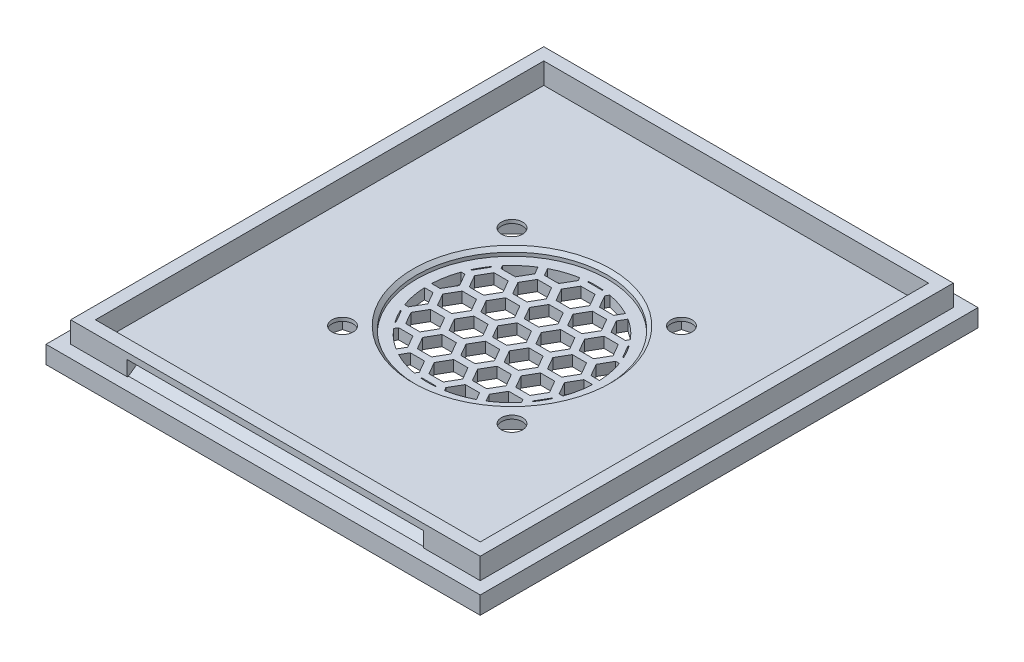
from build123d import *

# Parameters (mm, degrees)
SKETCH1_W           = 61.5
SKETCH1_H           = 70.5
SKETCH1_R           = 1.5
BOSS_EXTRUDE1_DEPTH = 2.5
SKETCH2_W           = 58
SKETCH2_H           = 67
SKETCH2_W_2         = 54.5
SKETCH2_H_2         = 63.5
BOSS_EXTRUDE2_DEPTH = 3
CUT_EXTRUDE1_DEPTH  = 2
SKETCH6_R           = 13.5
CUT_EXTRUDE7_DEPTH  = 1
CHAMFER1_SIZE       = 0.5
CUT_EXTRUDE8_DEPTH  = 1.5
CUT_EXTRUDE9_DEPTH  = 21


with BuildPart() as part:
    # Sketch1 → Boss-Extrude1 (new body)
    with BuildSketch(Plane(origin=(0, 0, 0), x_dir=(1, 0, 0), z_dir=(0, 1, 0))):
        Rectangle(SKETCH1_W, SKETCH1_H)
        with Locations((-12, 12)):
            Circle(SKETCH1_R, mode=Mode.SUBTRACT)
        with Locations((-12, -12)):
            Circle(SKETCH1_R, mode=Mode.SUBTRACT)
        with Locations((12, -12)):
            Circle(SKETCH1_R, mode=Mode.SUBTRACT)
        with Locations((12, 12)):
            Circle(SKETCH1_R, mode=Mode.SUBTRACT)
    extrude(amount=BOSS_EXTRUDE1_DEPTH)

    # Sketch2 → Boss-Extrude2 (add)
    with BuildSketch(Plane(origin=(0, 2.5, 0), x_dir=(1, 0, 0), z_dir=(0, 1, 0))):
        Rectangle(SKETCH2_W, SKETCH2_H)
        Rectangle(SKETCH2_W_2, SKETCH2_H_2, mode=Mode.SUBTRACT)
    extrude(amount=BOSS_EXTRUDE2_DEPTH)

    # Sketch3 → Cut-Extrude1 (cut)
    with BuildSketch(Plane.XZ):
        Polygon((-11.252853773, 9.211612321), (-9.211612321, 11.252853773), (-9.958758548, 14.041241452), (-12.747146227, 14.788387679), (-14.788387679, 12.747146227), (-14.041241452, 9.958758548), align=None)
        Polygon((9.211612321, 11.252853773), (11.252853773, 9.211612321), (14.041241452, 9.958758548), (14.788387679, 12.747146227), (12.747146227, 14.788387679), (9.958758548, 14.041241452), align=None)
        Polygon((11.252853773, -9.211612321), (9.211612321, -11.252853773), (9.958758548, -14.041241452), (12.747146227, -14.788387679), (14.788387679, -12.747146227), (14.041241452, -9.958758548), align=None)
        Polygon((-9.211612321, -11.252853773), (-11.252853773, -9.211612321), (-14.041241452, -9.958758548), (-14.788387679, -12.747146227), (-12.747146227, -14.788387679), (-9.958758548, -14.041241452), align=None)
    extrude(amount=-CUT_EXTRUDE1_DEPTH, mode=Mode.SUBTRACT)

    # Sketch6 → Cut-Extrude7 (cut)
    with BuildSketch(Plane(origin=(0, 2.5, 0), x_dir=(1, 0, 0), z_dir=(0, 1, 0))):
        Circle(SKETCH6_R)
    extrude(amount=-CUT_EXTRUDE7_DEPTH, mode=Mode.SUBTRACT)

    # Chamfer1
    chamfer1_edges = [part.edges().sort_by_distance(p)[0] for p in [
        (-13.5, 2.5, 0),
    ]]
    chamfer(chamfer1_edges, length=CHAMFER1_SIZE)

    # Sketch4 → Cut-Extrude8 (cut)
    with BuildSketch(Plane.XZ):
        with BuildLine():
            Line((10.680637029, 5), (10.804720311, 5))
            ThreePointArc((10.804720311, 5), (10.310421845, 5.952913772), (9.73229868, 6.857429796))
            Line((9.73229868, 6.857429796), (9.670274058, 6.75))
            Line((9.670274058, 6.75), (10.680637029, 5))
        make_face()
        with BuildLine():
            Line((10.680637029, 0.5), (11.895040185, 0.5))
            ThreePointArc((11.895040185, 0.5), (11.686032158, 2.275661089), (11.213473191, 4))
            Line((11.213473191, 4), (10.680637029, 4))
            Line((10.680637029, 4), (9.670274058, 2.25))
            Line((9.670274058, 2.25), (10.680637029, 0.5))
        make_face()
        Polygon((6.783637029, 2.75), (8.804362971, 2.75), (9.814725942, 4.5), (8.804362971, 6.25), (6.783637029, 6.25), (5.773274058, 4.5), align=None)
        with BuildLine():
            Line((8.804362971, 7.25), (9.070702049, 7.711312815))
            ThreePointArc((9.070702049, 7.711312815), (7.813642325, 8.982704193), (6.380365479, 10.051513187))
            Line((6.380365479, 10.051513187), (5.773274058, 9))
            Line((5.773274058, 9), (6.783637029, 7.25))
            Line((6.783637029, 7.25), (8.804362971, 7.25))
        make_face()
        Polygon((6.783637029, -1.75), (8.804362971, -1.75), (9.814725942, 0), (8.804362971, 1.75), (6.783637029, 1.75), (5.773274058, 0), align=None)
        with BuildLine():
            Line((10.680637029, -4), (11.213473191, -4))
            ThreePointArc((11.213473191, -4), (11.686032158, -2.275661089), (11.895040185, -0.5))
            Line((11.895040185, -0.5), (10.680637029, -0.5))
            Line((10.680637029, -0.5), (9.670274058, -2.25))
            Line((9.670274058, -2.25), (10.680637029, -4))
        make_face()
        Polygon((6.783637029, -6.25), (8.804362971, -6.25), (9.814725942, -4.5), (8.804362971, -2.75), (6.783637029, -2.75), (5.773274058, -4.5), align=None)
        with BuildLine():
            Line((5.773274058, -9), (6.380365479, -10.051513187))
            ThreePointArc((6.380365479, -10.051513187), (7.813642325, -8.982704193), (9.070702049, -7.711312815))
            Line((9.070702049, -7.711312815), (8.804362971, -7.25))
            Line((8.804362971, -7.25), (6.783637029, -7.25))
            Line((6.783637029, -7.25), (5.773274058, -9))
        make_face()
        with BuildLine():
            Line((1.876274058, -11.25), (2.142531585, -11.711171564))
            ThreePointArc((2.142531585, -11.711171564), (3.872139217, -11.25826447), (5.514419572, -10.551452876))
            Line((5.514419572, -10.551452876), (4.907362971, -9.5))
            Line((4.907362971, -9.5), (2.886637029, -9.5))
            Line((2.886637029, -9.5), (1.876274058, -11.25))
        make_face()
        Polygon((2.886637029, -5), (1.876274058, -6.75), (2.886637029, -8.5), (4.907362971, -8.5), (5.917725942, -6.75), (4.907362971, -5), align=None)
        Polygon((4.907362971, -0.5), (2.886637029, -0.5), (1.876274058, -2.25), (2.886637029, -4), (4.907362971, -4), (5.917725942, -2.25), align=None)
        Polygon((2.886637029, 4), (1.876274058, 2.25), (2.886637029, 0.5), (4.907362971, 0.5), (5.917725942, 2.25), (4.907362971, 4), align=None)
        Polygon((2.886637029, 8.5), (1.876274058, 6.75), (2.886637029, 5), (4.907362971, 5), (5.917725942, 6.75), (4.907362971, 8.5), align=None)
        with BuildLine():
            Line((4.907362971, 9.5), (5.514419572, 10.551452876))
            ThreePointArc((5.514419572, 10.551452876), (3.872139217, 11.25826447), (2.142531585, 11.711171564))
            Line((2.142531585, 11.711171564), (1.876274058, 11.25))
            Line((1.876274058, 11.25), (2.886637029, 9.5))
            Line((2.886637029, 9.5), (4.907362971, 9.5))
        make_face()
        Polygon((-1.010362971, 7.25), (1.010362971, 7.25), (2.020725942, 9), (1.010362971, 10.75), (-1.010362971, 10.75), (-2.020725942, 9), align=None)
        Polygon((-1.010362971, 2.75), (1.010362971, 2.75), (2.020725942, 4.5), (1.010362971, 6.25), (-1.010362971, 6.25), (-2.020725942, 4.5), align=None)
        Polygon((-1.010362971, 1.75), (-2.020725942, 0), (2.020725942, 0), (1.010362971, 1.75), align=None)
        Polygon((-2.020725942, 0), (2.020725942, 0), (1.010362971, -1.75), (-1.010362971, -1.75), align=None)
        Polygon((-1.010362971, -6.25), (1.010362971, -6.25), (2.020725942, -4.5), (1.010362971, -2.75), (-1.010362971, -2.75), (-2.020725942, -4.5), align=None)
        Polygon((-1.010362971, -10.75), (1.010362971, -10.75), (2.020725942, -9), (1.010362971, -7.25), (-1.010362971, -7.25), (-2.020725942, -9), align=None)
        with BuildLine():
            Line((-5.514419572, -10.551452876), (-4.907362971, -9.5))
            Line((-4.907362971, -9.5), (-2.886637029, -9.5))
            Line((-2.886637029, -9.5), (-1.876274058, -11.25))
            Line((-1.876274058, -11.25), (-2.142531585, -11.711171564))
            ThreePointArc((-2.142531585, -11.711171564), (-3.872139217, -11.25826447), (-5.514419572, -10.551452876))
        make_face()
        Polygon((-2.886637029, -8.5), (-4.907362971, -8.5), (-5.917725942, -6.75), (-4.907362971, -5), (-2.886637029, -5), (-1.876274058, -6.75), align=None)
        Polygon((-1.876274058, -2.25), (-2.886637029, -4), (-4.907362971, -4), (-5.917725942, -2.25), (-4.907362971, -0.5), (-2.886637029, -0.5), align=None)
        Polygon((-2.886637029, 0.5), (-4.907362971, 0.5), (-5.917725942, 2.25), (-4.907362971, 4), (-2.886637029, 4), (-1.876274058, 2.25), align=None)
        Polygon((-2.886637029, 5), (-4.907362971, 5), (-5.917725942, 6.75), (-4.907362971, 8.5), (-2.886637029, 8.5), (-1.876274058, 6.75), align=None)
        with BuildLine():
            Line((-2.142531585, 11.711171564), (-1.876274058, 11.25))
            Line((-1.876274058, 11.25), (-2.886637029, 9.5))
            Line((-2.886637029, 9.5), (-4.907362971, 9.5))
            Line((-4.907362971, 9.5), (-5.514419572, 10.551452876))
            ThreePointArc((-5.514419572, 10.551452876), (-3.872139217, 11.25826447), (-2.142531585, 11.711171564))
        make_face()
        with BuildLine():
            Line((-6.380365479, 10.051513187), (-5.773274058, 9))
            Line((-5.773274058, 9), (-6.783637029, 7.25))
            Line((-6.783637029, 7.25), (-8.804362971, 7.25))
            Line((-8.804362971, 7.25), (-9.070702049, 7.711312815))
            ThreePointArc((-9.070702049, 7.711312815), (-7.813642325, 8.982704193), (-6.380365479, 10.051513187))
        make_face()
        Polygon((-9.814725942, 4.5), (-8.804362971, 6.25), (-6.783637029, 6.25), (-5.773274058, 4.5), (-6.783637029, 2.75), (-8.804362971, 2.75), align=None)
        Polygon((-9.814725942, 0), (-8.804362971, 1.75), (-6.783637029, 1.75), (-5.773274058, 0), (-6.783637029, -1.75), (-8.804362971, -1.75), align=None)
        Polygon((-9.814725942, -4.5), (-8.804362971, -2.75), (-6.783637029, -2.75), (-5.773274058, -4.5), (-6.783637029, -6.25), (-8.804362971, -6.25), align=None)
        with BuildLine():
            Line((-9.070702049, -7.711312815), (-8.804362971, -7.25))
            Line((-8.804362971, -7.25), (-6.783637029, -7.25))
            Line((-6.783637029, -7.25), (-5.773274058, -9))
            Line((-5.773274058, -9), (-6.380365479, -10.051513187))
            ThreePointArc((-6.380365479, -10.051513187), (-7.813642325, -8.982704193), (-9.070702049, -7.711312815))
        make_face()
        with BuildLine():
            Line((-11.895040185, -0.5), (-10.680637029, -0.5))
            Line((-10.680637029, -0.5), (-9.670274058, -2.25))
            Line((-9.670274058, -2.25), (-10.680637029, -4))
            Line((-10.680637029, -4), (-11.213473191, -4))
            ThreePointArc((-11.213473191, -4), (-11.686032158, -2.275661089), (-11.895040185, -0.5))
        make_face()
        with BuildLine():
            Line((-11.213473191, 4), (-10.680637029, 4))
            Line((-10.680637029, 4), (-9.670274058, 2.25))
            Line((-9.670274058, 2.25), (-10.680637029, 0.5))
            Line((-10.680637029, 0.5), (-11.895040185, 0.5))
            ThreePointArc((-11.895040185, 0.5), (-11.686032158, 2.275661089), (-11.213473191, 4))
        make_face()
        with BuildLine():
            Line((10.680637029, -5), (9.670274058, -6.75))
            Line((9.670274058, -6.75), (9.73229868, -6.857429796))
            ThreePointArc((9.73229868, -6.857429796), (10.310421845, -5.952913772), (10.804720311, -5))
            Line((10.804720311, -5), (10.680637029, -5))
        make_face()
        with BuildLine():
            Line((-1.010362971, 11.75), (1.010362971, 11.75))
            Line((1.010362971, 11.75), (1.072233137, 11.85716227))
            ThreePointArc((1.072233137, 11.85716227), (0, 11.905544129), (-1.072233137, 11.85716227))
            Line((-1.072233137, 11.85716227), (-1.010362971, 11.75))
        make_face()
        with BuildLine():
            Line((1.010362971, -11.75), (-1.010362971, -11.75))
            Line((-1.010362971, -11.75), (-1.072233137, -11.85716227))
            ThreePointArc((-1.072233137, -11.85716227), (0, -11.905544129), (1.072233137, -11.85716227))
            Line((1.072233137, -11.85716227), (1.010362971, -11.75))
        make_face()
        with BuildLine():
            ThreePointArc((-10.804720311, -5), (-10.310421845, -5.952913772), (-9.73229868, -6.857429796))
            Line((-9.73229868, -6.857429796), (-9.670274058, -6.75))
            Line((-9.670274058, -6.75), (-10.680637029, -5))
            Line((-10.680637029, -5), (-10.804720311, -5))
        make_face()
        with BuildLine():
            ThreePointArc((-9.73229868, 6.857429796), (-10.310421845, 5.952913772), (-10.804720311, 5))
            Line((-10.804720311, 5), (-10.680637029, 5))
            Line((-10.680637029, 5), (-9.670274058, 6.75))
            Line((-9.670274058, 6.75), (-9.73229868, 6.857429796))
        make_face()
    extrude(amount=-CUT_EXTRUDE8_DEPTH, mode=Mode.SUBTRACT)

    # Sketch7 → Cut-Extrude9 (cut, symmetric)
    with BuildSketch(Plane(origin=(0, 0, 0), x_dir=(0, 0, -1), z_dir=(1, 0, 0))):
        Polygon((-33.325, 2.5), (-33.6, 2.5), (-33.6, 4.691485422), (-31.888859338, 3.5), align=None)
        Polygon((33.6, 4.691485422), (31.888859338, 3.5), (33.325, 2.5), (33.6, 2.5), align=None)
    extrude(amount=CUT_EXTRUDE9_DEPTH, both=True, mode=Mode.SUBTRACT)


solid = part.part
